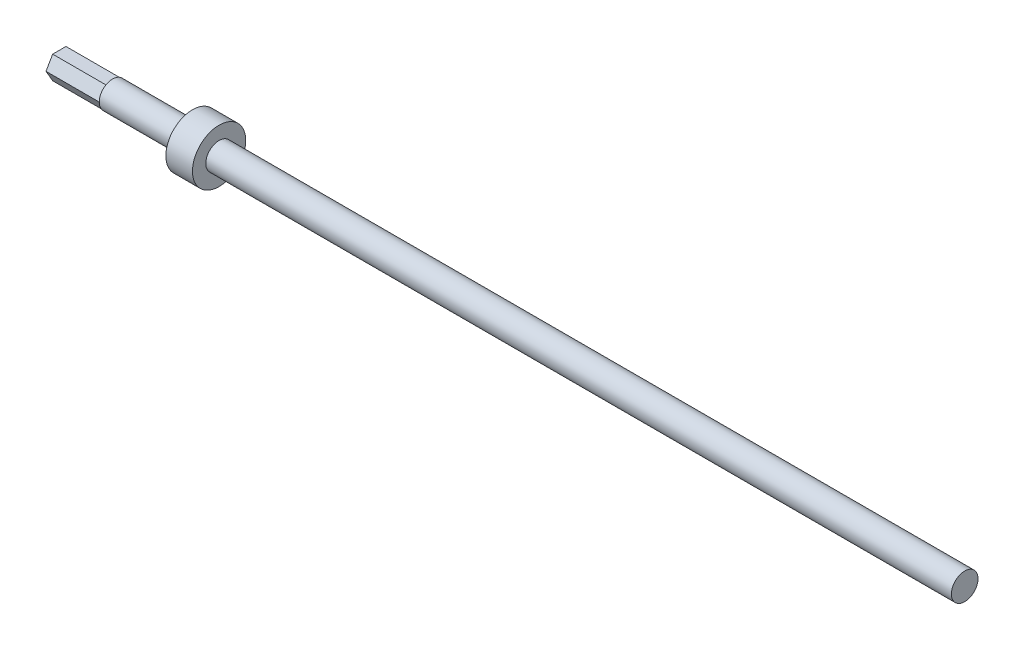
from build123d import *

# Parameters (mm, degrees)
BOSS_EXTRUDE1_DEPTH = 25.4


with BuildPart() as part:
    # Sketch1 → Revolve1 (revolve)
    with BuildSketch(Plane.XY):
        Polygon((369.219639575, 6.35), (369.219639575, 0), (-37.180360425, 0), (-37.180360425, 6.35), (0.919639575, 6.35), (0.919639575, 12.7), (13.619639575, 12.7), (13.619639575, 6.35), align=None)
    revolve(axis=Axis((-42.05584448, 0, 0), (1, 0, 0)))

    # Sketch2 → Boss-Extrude1 (add)
    with BuildSketch(Plane.ZY.offset(37.180360425)):
        Polygon((3.175, -5.499261314), (6.35, 0), (3.175, 5.499261314), (-3.175, 5.499261314), (-6.35, 0), (-3.175, -5.499261314), align=None)
    extrude(amount=BOSS_EXTRUDE1_DEPTH)


solid = part.part
